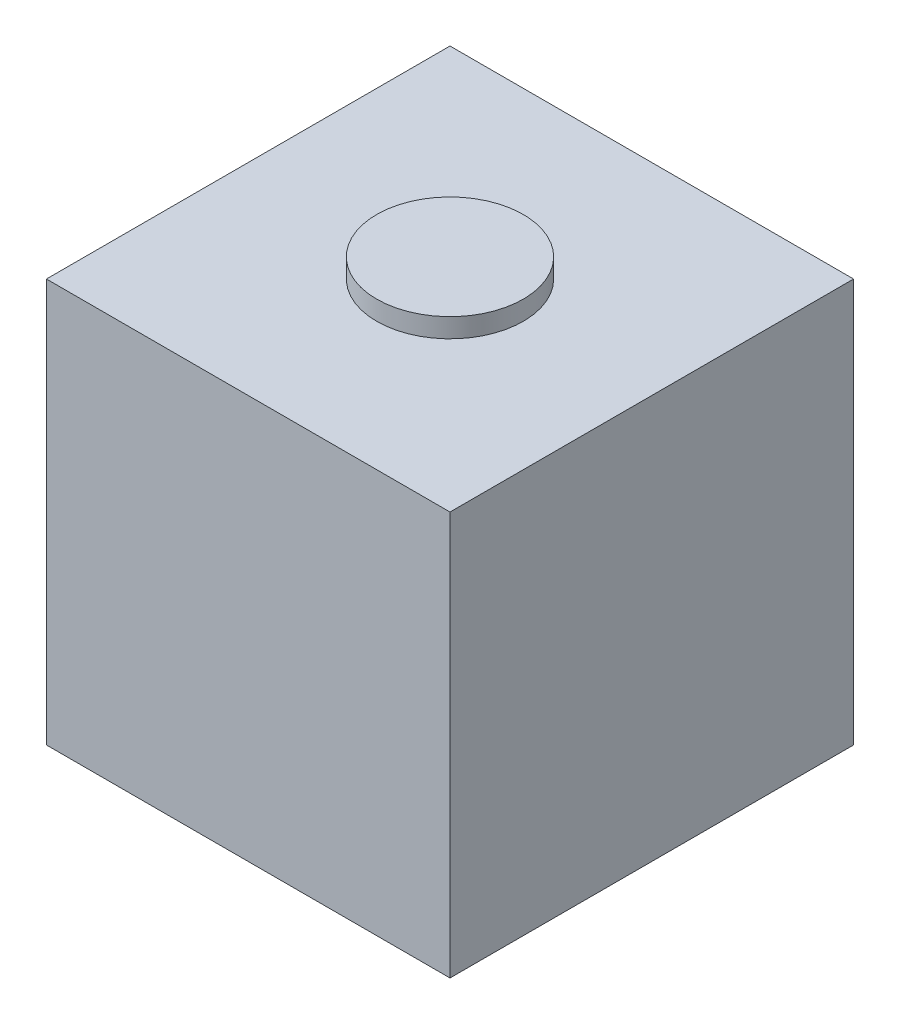
from build123d import *

# Parameters (mm, degrees)
SKETCH1_W           = 42
SKETCH1_H           = 42
BOSS_EXTRUDE1_DEPTH = 42
SKETCH2_R           = 7.63094392
BOSS_EXTRUDE2_DEPTH = 2


with BuildPart() as part:
    # Sketch1 → Boss-Extrude1 (new body)
    with BuildSketch(Plane(origin=(0, 0, 0), x_dir=(1, 0, 0), z_dir=(0, 1, 0))):
        Rectangle(SKETCH1_W, SKETCH1_H)
    extrude(amount=BOSS_EXTRUDE1_DEPTH)

    # Sketch2 → Boss-Extrude2 (add)
    with BuildSketch(Plane(origin=(0, 42, 0), x_dir=(1, 0, 0), z_dir=(0, 1, 0))):
        Circle(SKETCH2_R)
    extrude(amount=BOSS_EXTRUDE2_DEPTH)


solid = part.part
